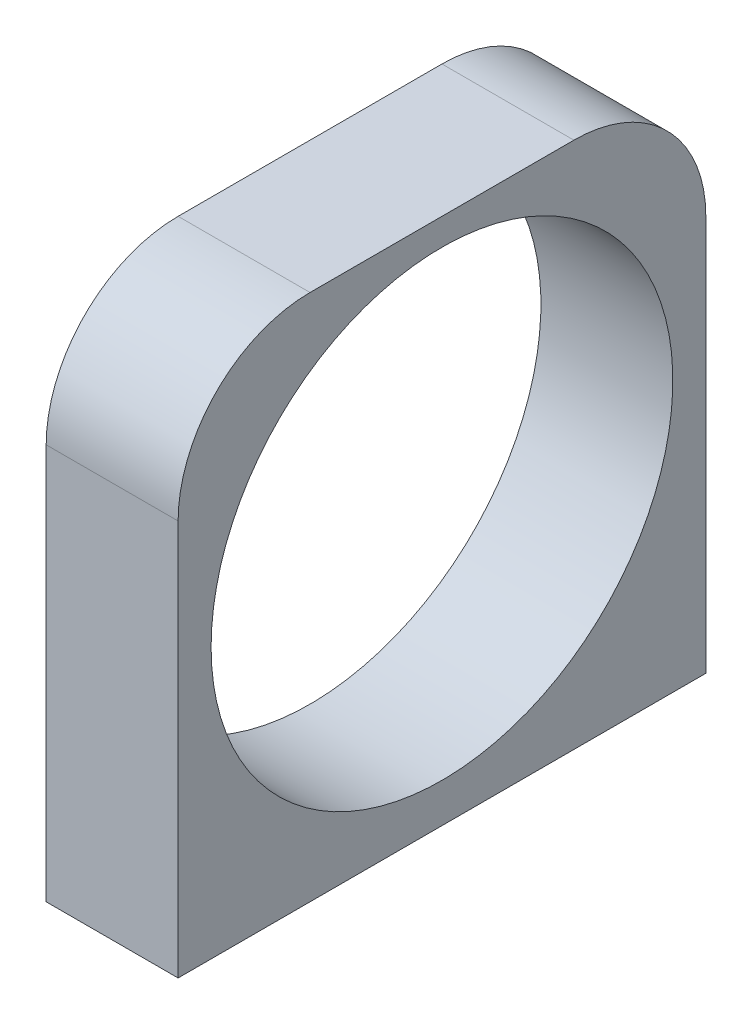
from build123d import *

# Parameters (mm, degrees)
SKETCH1_W           = 6.35
SKETCH1_H           = 25.4
BOSS_EXTRUDE1_DEPTH = 25.4
FILLET1_R           = 6.35
SKETCH2_R           = 11.1125
CUT_EXTRUDE1_DEPTH  = 7.35


with BuildPart() as part:
    # Sketch1 → Boss-Extrude1 (new body)
    with BuildSketch(Plane(origin=(0, 0, 0), x_dir=(1, 0, 0), z_dir=(0, 1, 0))):
        Rectangle(SKETCH1_W, SKETCH1_H)
    extrude(amount=BOSS_EXTRUDE1_DEPTH)

    # Fillet1
    fillet1_edges = [part.edges().sort_by_distance(p)[0] for p in [
        (0, 25.4, 12.7),
        (0, 25.4, -12.7),
    ]]
    fillet(fillet1_edges, radius=FILLET1_R)

    # Sketch2 → Cut-Extrude1 (cut, through all)
    with BuildSketch(Plane.ZY.offset(3.175)):
        with Locations((0, 13)):
            Circle(SKETCH2_R)
    extrude(amount=-CUT_EXTRUDE1_DEPTH, mode=Mode.SUBTRACT)


solid = part.part
